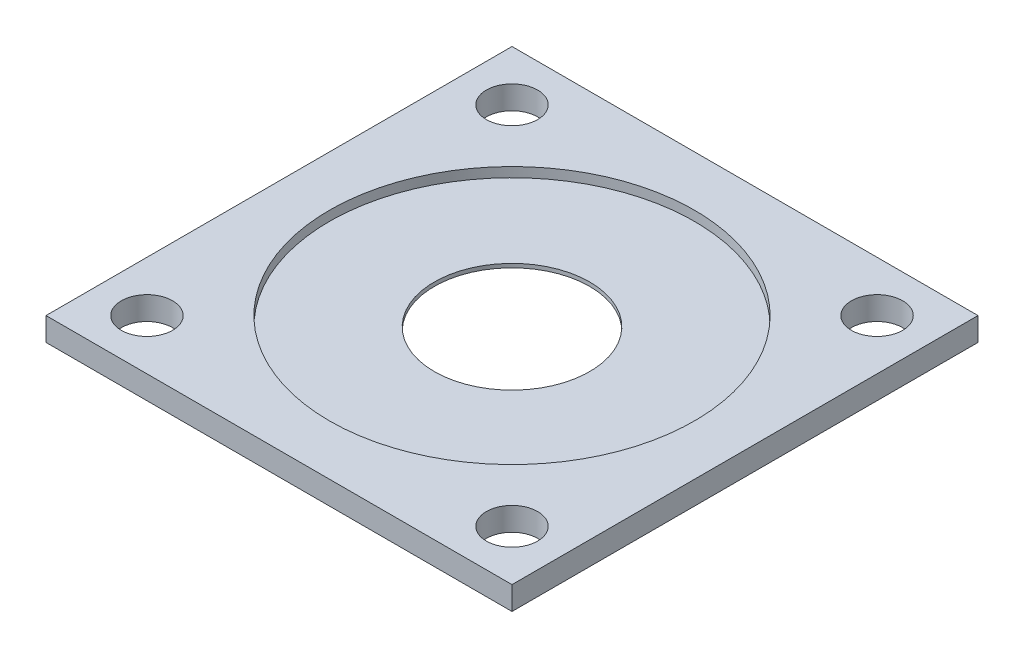
from build123d import *

# Parameters (mm, degrees)
SKETCH2_W           = 60
SKETCH2_H           = 60
SKETCH2_R           = 23.5
SKETCH2_R_2         = 3.3
BOSS_EXTRUDE1_DEPTH = 1.5
BOSS_EXTRUDE2_START = -0.25
SKETCH2_3_R         = 23.5
SKETCH2_3_R_2       = 10
BOSS_EXTRUDE2_DEPTH = 0.5


with BuildPart() as part:
    # Sketch2 → Boss-Extrude1 (new body, symmetric)
    with BuildSketch(Plane(origin=(0, 0, 0), x_dir=(1, 0, 0), z_dir=(0, 1, 0))):
        Rectangle(SKETCH2_W, SKETCH2_H)
        Circle(SKETCH2_R, mode=Mode.SUBTRACT)
        with Locations((23.5, 23.5)):
            Circle(SKETCH2_R_2, mode=Mode.SUBTRACT)
        with Locations((-23.5, 23.5)):
            Circle(SKETCH2_R_2, mode=Mode.SUBTRACT)
        with Locations((23.5, -23.5)):
            Circle(SKETCH2_R_2, mode=Mode.SUBTRACT)
        with Locations((-23.5, -23.5)):
            Circle(SKETCH2_R_2, mode=Mode.SUBTRACT)
    extrude(amount=BOSS_EXTRUDE1_DEPTH, both=True)

    # Sketch2_3 → Boss-Extrude2 (add)
    with BuildSketch(Plane(origin=(0, 0, 0), x_dir=(1, 0, 0), z_dir=(0, 1, 0)).offset(BOSS_EXTRUDE2_START)):
        Circle(SKETCH2_3_R)
        Circle(SKETCH2_3_R_2, mode=Mode.SUBTRACT)
    extrude(amount=BOSS_EXTRUDE2_DEPTH)


solid = part.part
